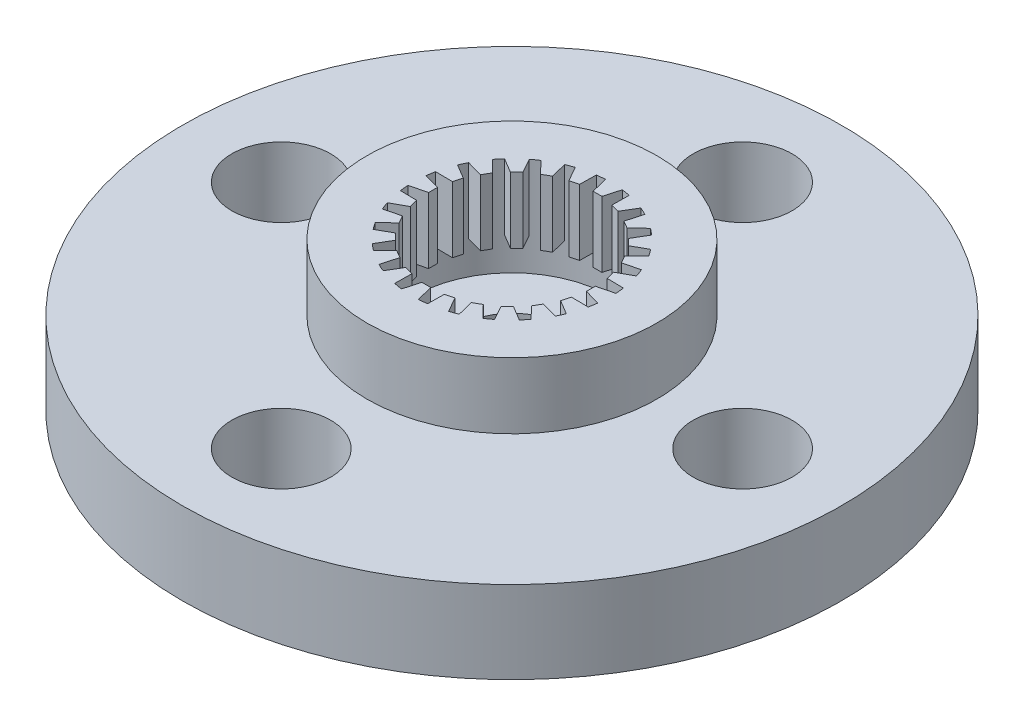
from build123d import *

# Parameters (mm, degrees)
SKETCH_4_R               = 10
EXTRUDE_2_DEPTH          = 2.5
SKETCH_6_R               = 1.5
CUT_EXTRUDE_9_DEPTH      = 2.5
SKETCH_7_R               = 4.4
EXTRUDE_3_DEPTH          = 2
SKETCH_8_R               = 3
CUT_EXTRUDE_10_DEPTH     = 3
EXTRUDE_5_DEPTH          = 2
PATTERN_CIRCULAR_1_COUNT = 24


with BuildPart() as part:
    # 草图4 → 凸台-拉伸2 (new body)
    with BuildSketch(Plane(origin=(0, 0, 0), x_dir=(1, 0, 0), z_dir=(0, 1, 0))):
        Circle(SKETCH_4_R)
    extrude(amount=EXTRUDE_2_DEPTH)

    # 草图6 → 切除-拉伸9 (cut)
    with BuildSketch(Plane(origin=(0, 2.5, 0), x_dir=(1, 0, 0), z_dir=(0, 1, 0))):
        with Locations((0, 7)):
            Circle(SKETCH_6_R)
        Circle(SKETCH_6_R)
        with Locations((7, 0)):
            Circle(SKETCH_6_R)
        with Locations((-7, 0)):
            Circle(SKETCH_6_R)
        with Locations((0, -7)):
            Circle(SKETCH_6_R)
    extrude(amount=-CUT_EXTRUDE_9_DEPTH, mode=Mode.SUBTRACT)

    # 草图7 → 凸台-拉伸3 (add)
    with BuildSketch(Plane(origin=(0, 2.5, 0), x_dir=(1, 0, 0), z_dir=(0, 1, 0))):
        Circle(SKETCH_7_R)
    extrude(amount=EXTRUDE_3_DEPTH)

    # 草图8 → 切除-拉伸10 (cut)
    with BuildSketch(Plane(origin=(0, 4.5, 0), x_dir=(1, 0, 0), z_dir=(0, 1, 0))):
        Circle(SKETCH_8_R)
    extrude(amount=-CUT_EXTRUDE_10_DEPTH, mode=Mode.SUBTRACT)

    # 草图14 → 凸台-拉伸5 (add)
    with BuildSketch(Plane(origin=(0, 4.5, 0), x_dir=(1, 0, 0), z_dir=(0, 1, 0))):
        with BuildLine():
            Line((2.976910005, -0.371492698), (2.495792863, -0.23538136))
            Line((2.495792863, -0.23538136), (2.495792863, 0.032272898))
            Line((2.495792863, 0.032272898), (2.995792863, 0.158824181))
            ThreePointArc((2.995792863, 0.158824181), (2.998100046, -0.106752588), (2.976910005, -0.371492698))
        make_face()
    extrude_5 = extrude(amount=-EXTRUDE_5_DEPTH)

    # 阵列(圆周)1: 凸台-拉伸5 ×24 about axis
    pattern_circular_1_axis = Axis((0, 4.5, 0), (0, 1, 0))
    for i in range(1, PATTERN_CIRCULAR_1_COUNT):
        add(extrude_5.rotate(pattern_circular_1_axis, i * 360 / PATTERN_CIRCULAR_1_COUNT))


solid = part.part
